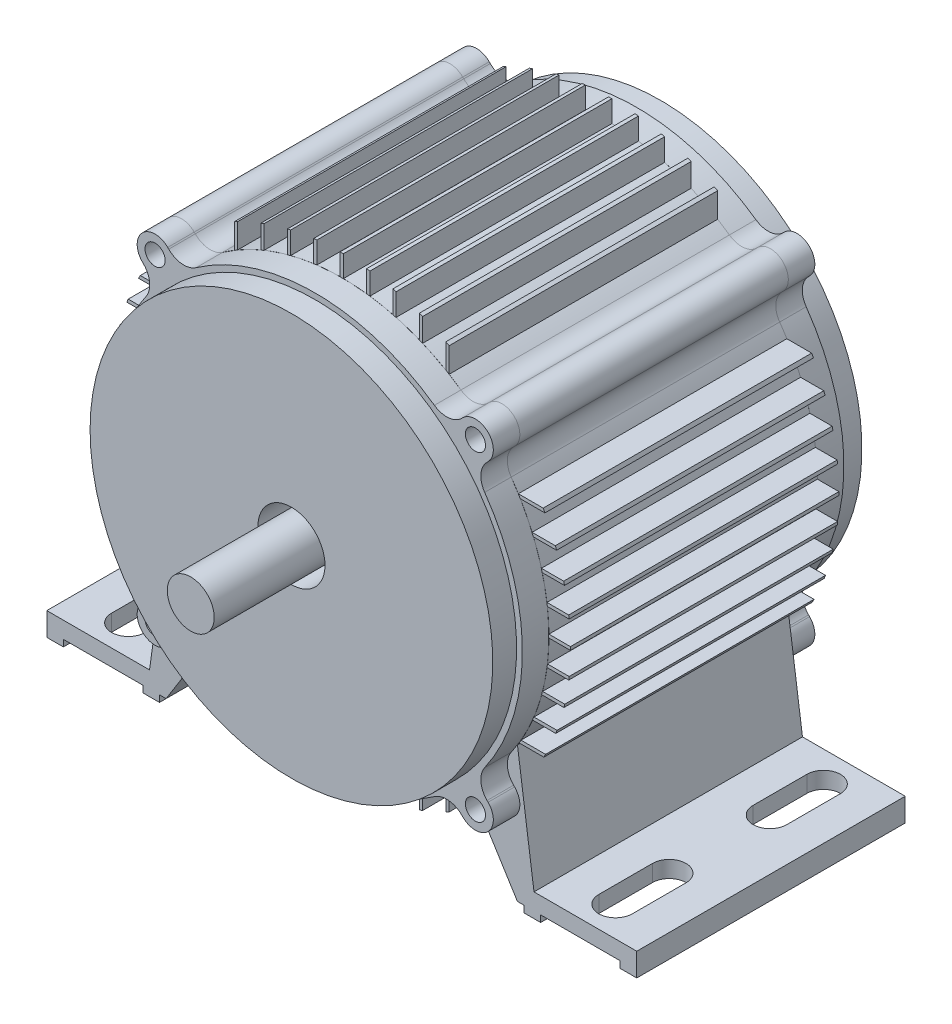
from build123d import *

# Parameters (mm, degrees)
SKETCH2_R           = 3.001904892
BOSS_EXTRUDE1_DEPTH = 40
SKETCH3_R           = 3.001904892
BOSS_EXTRUDE2_DEPTH = 7.90123449
SKETCH4_R           = 60
BOSS_EXTRUDE3_DEPTH = 7.09876741
SKETCH5_R           = 10
CUT_EXTRUDE1_DEPTH  = 10
SKETCH6_R           = 7
BOSS_EXTRUDE4_DEPTH = 40
CUT_EXTRUDE2_DEPTH  = 7.913590238


with BuildPart() as part:
    # Sketch2 → Boss-Extrude1 (new body, symmetric)
    with BuildSketch(Plane.XY):
        with BuildLine():
            Line((-51.501415301, 43.958000159), (-51.19613283, 43.652717688))
            ThreePointArc((-51.19613283, 43.652717688), (-49.359859691, 39.709533744), (-50.492135081, 35.509706236))
            ThreePointArc((-50.492135081, 35.509706236), (-51.583521776, 33.904796461), (-52.623914304, 32.266369261))
            Line((-52.623914304, 32.266369261), (-60.023406434, 32.266366121))
            ThreePointArc((-60.023406434, 32.266366121), (-60.2857042, 31.773598658), (-60.543956635, 31.278699103))
            Line((-60.543956635, 31.278699103), (-53.216893089, 31.278718144))
            ThreePointArc((-53.216893089, 31.278718144), (-55.075175316, 27.876889761), (-56.71627077, 24.365130246))
            Line((-56.71627077, 24.365130246), (-63.641714651, 24.365136135))
            ThreePointArc((-63.641714651, 24.365136135), (-63.828318371, 23.872022883), (-64.011101381, 23.377480672))
            Line((-64.011101381, 23.377480672), (-57.130453877, 23.377471671))
            ThreePointArc((-57.130453877, 23.377471671), (-58.413752932, 19.955661112), (-59.492308567, 16.463904862))
            Line((-59.492308567, 16.463904862), (-66.127663112, 16.463896075))
            ThreePointArc((-66.127663112, 16.463896075), (-66.248550527, 15.970512068), (-66.365756817, 15.476240653))
            Line((-66.365756817, 15.476240653), (-59.756854028, 15.47624901))
            ThreePointArc((-59.756854028, 15.47624901), (-60.550785596, 11.999927103), (-61.142654022, 8.48356064))
            Line((-61.142654022, 8.48356064), (-67.616248118, 8.483554267))
            ThreePointArc((-67.616248118, 8.483554267), (-67.676351394, 7.989941467), (-67.732851241, 7.495903243))
            Line((-67.732851241, 7.495903243), (-61.27157941, 7.495898782))
            ThreePointArc((-61.27157941, 7.495898782), (-61.595689717, 4.045485161), (-61.725649816, 0.58232013))
            Line((-61.725649816, 0.58232013), (-68.14388164, 0.582320874))
            ThreePointArc((-68.14388164, 0.582320874), (-68.146312234, 0.088496103), (-68.145164227, -0.405333315))
            Line((-68.145164227, -0.405333315), (-61.727065744, -0.405335092))
            ThreePointArc((-61.727065744, -0.405335092), (-61.607076082, -3.868219042), (-61.29297209, -7.318914833))
            Line((-61.29297209, -7.318914833), (-67.752204396, -7.318914))
            ThreePointArc((-67.752204396, -7.318914), (-67.697012719, -7.812948967), (-67.63821869, -8.306568185))
            Line((-67.63821869, -8.306568185), (-61.166950622, -8.306569298))
            ThreePointArc((-61.166950622, -8.306569298), (-60.603001045, -11.733337387), (-59.8472251, -15.122965889))
            Line((-59.8472251, -15.122965889), (-66.447149122, -15.12296519))
            ThreePointArc((-66.447149122, -15.12296519), (-66.332721065, -15.617228269), (-66.214616514, -16.110625762))
            Line((-66.214616514, -16.110625762), (-59.588945291, -16.110619219))
            ThreePointArc((-59.588945291, -16.110619219), (-58.533502121, -19.601621923), (-57.273737991, -23.024202017))
            Line((-57.273737991, -23.024202017), (-64.139023113, -23.024191988))
            ThreePointArc((-64.139023113, -23.024191988), (-63.959343175, -23.51871857), (-63.775850389, -24.011843116))
            Line((-63.775850389, -24.011843116), (-56.866737161, -24.011854294))
            ThreePointArc((-56.866737161, -24.011854294), (-55.253087395, -27.522559388), (-53.422959101, -30.925432622))
            Line((-53.422959101, -30.925432622), (-60.725164552, -30.925427932))
            ThreePointArc((-60.725164552, -30.925427932), (-60.470588944, -31.420305145), (-60.211980439, -31.91308688))
            Line((-60.211980439, -31.91308688), (-52.83890994, -31.913084215))
            ThreePointArc((-52.83890994, -31.913084215), (-52.600187977, -32.305039429), (-52.358555779, -32.695207274))
            Line((-52.358555779, -32.695207274), (-57.28396266, -68.148145721))
            Line((-57.28396266, -68.148145721), (-87.901233697, -68.148147473))
            Line((-87.901233697, -68.148147473), (-87.901233697, -75.061727651))
            Line((-87.901233697, -75.061727651), (-82.962962141, -75.061727651))
            Line((-82.962962141, -75.061727651), (-82.962962141, -73.086419029))
            Line((-82.962962141, -73.086419029), (-59.259258672, -73.086419029))
            Line((-59.259258672, -73.086419029), (-59.259258672, -75.061727651))
            Line((-59.259258672, -75.061727651), (-54.320987116, -75.061727651))
            Line((-54.320987116, -75.061727651), (-54.320987116, -73.086419029))
            Line((-54.320987116, -73.086419029), (-52.345682251, -73.086416681))
            Line((-52.345682251, -73.086416681), (-37.372511824, -49.129322221))
            ThreePointArc((-37.372511824, -49.129322221), (-34.735133697, -51.028084709), (-32.001482108, -52.785415456))
            Line((-32.001482108, -52.785415456), (-32.001488085, -60.16504353))
            ThreePointArc((-32.001488085, -60.16504353), (-31.508713442, -60.424570167), (-31.013834243, -60.680060878))
            Line((-31.013834243, -60.680060878), (-31.013830274, -53.371689815))
            ThreePointArc((-31.013830274, -53.371689815), (-27.611209789, -55.208840197), (-24.100235977, -56.829337211))
            Line((-24.100235977, -56.829337211), (-24.100239197, -63.742498957))
            ThreePointArc((-24.100239197, -63.742498957), (-23.607122651, -63.926766403), (-23.11259739, -64.107219129))
            Line((-23.11259739, -64.107219129), (-23.112585448, -57.23812834))
            ThreePointArc((-23.112585448, -57.23812834), (-19.690202448, -58.503767994), (-16.199016562, -59.564979681))
            Line((-16.199016562, -59.564979681), (-16.199011276, -66.193049003))
            ThreePointArc((-16.199011276, -66.193049003), (-15.705621383, -66.311847807), (-15.211360474, -66.426969035))
            Line((-15.211360474, -66.426969035), (-15.21136167, -59.824822759))
            ThreePointArc((-15.21136167, -59.824822759), (-11.821929932, -60.585781456), (-8.395058809, -61.154868404))
            Line((-8.395058809, -61.154868404), (-8.395063641, -67.627291895))
            ThreePointArc((-8.395063641, -67.627291895), (-7.901445328, -67.686740683), (-7.407406427, -67.742586551))
            Line((-7.407406427, -67.742586551), (-7.407405553, -61.282344658))
            ThreePointArc((-7.407405553, -61.282344658), (-3.95685085, -61.601450918), (-0.493826306, -61.726421227))
            Line((-0.493826306, -61.726421227), (-0.493827155, -68.144580396))
            ThreePointArc((-0.493827155, -68.144580396), (0, -68.146369695), (0.493827155, -68.144580396))
            Line((0.493827155, -68.144580396), (0.493826306, -61.726421227))
            ThreePointArc((0.493826306, -61.726421227), (3.95685085, -61.601450918), (7.407405553, -61.282344658))
            Line((7.407405553, -61.282344658), (7.407406427, -67.742586551))
            ThreePointArc((7.407406427, -67.742586551), (7.901445328, -67.686740683), (8.395063641, -67.627291895))
            Line((8.395063641, -67.627291895), (8.395058809, -61.154868404))
            ThreePointArc((8.395058809, -61.154868404), (11.821929932, -60.585781456), (15.21136167, -59.824822759))
            Line((15.21136167, -59.824822759), (15.211360474, -66.426969035))
            ThreePointArc((15.211360474, -66.426969035), (15.705621383, -66.311847807), (16.199011276, -66.193049003))
            Line((16.199011276, -66.193049003), (16.199016562, -59.564979681))
            ThreePointArc((16.199016562, -59.564979681), (19.690202448, -58.503767994), (23.112585448, -57.23812834))
            Line((23.112585448, -57.23812834), (23.11259739, -64.107219129))
            ThreePointArc((23.11259739, -64.107219129), (23.607122651, -63.926766403), (24.100239197, -63.742498957))
            Line((24.100239197, -63.742498957), (24.100235977, -56.829337211))
            ThreePointArc((24.100235977, -56.829337211), (27.611209789, -55.208840197), (31.013830274, -53.371689815))
            Line((31.013830274, -53.371689815), (31.013834243, -60.680060878))
            ThreePointArc((31.013834243, -60.680060878), (31.508713442, -60.424570167), (32.001488085, -60.16504353))
            Line((32.001488085, -60.16504353), (32.001482108, -52.785415456))
            ThreePointArc((32.001482108, -52.785415456), (34.735133697, -51.028084709), (37.372511824, -49.129322221))
            Line((37.372511824, -49.129322221), (52.345682251, -73.086416681))
            Line((52.345682251, -73.086416681), (54.320987116, -73.086419029))
            Line((54.320987116, -73.086419029), (54.320987116, -75.061727651))
            Line((54.320987116, -75.061727651), (59.259258672, -75.061727651))
            Line((59.259258672, -75.061727651), (59.259258672, -73.086419029))
            Line((59.259258672, -73.086419029), (82.962962141, -73.086419029))
            Line((82.962962141, -73.086419029), (82.962962141, -75.061727651))
            Line((82.962962141, -75.061727651), (87.901233697, -75.061727651))
            Line((87.901233697, -75.061727651), (87.901233697, -68.148147473))
            Line((87.901233697, -68.148147473), (57.28396266, -68.148145721))
            Line((57.28396266, -68.148145721), (52.358555779, -32.695207274))
            ThreePointArc((52.358555779, -32.695207274), (52.600187977, -32.305039429), (52.83890994, -31.913084215))
            Line((52.83890994, -31.913084215), (60.211980439, -31.91308688))
            ThreePointArc((60.211980439, -31.91308688), (60.470588944, -31.420305145), (60.725164552, -30.925427932))
            Line((60.725164552, -30.925427932), (53.422959101, -30.925432622))
            ThreePointArc((53.422959101, -30.925432622), (55.253087395, -27.522559388), (56.866737161, -24.011854294))
            Line((56.866737161, -24.011854294), (63.775850389, -24.011843116))
            ThreePointArc((63.775850389, -24.011843116), (63.959343175, -23.51871857), (64.139023113, -23.024191988))
            Line((64.139023113, -23.024191988), (57.273737991, -23.024202017))
            ThreePointArc((57.273737991, -23.024202017), (58.533502121, -19.601621923), (59.588945291, -16.110619219))
            Line((59.588945291, -16.110619219), (66.214616514, -16.110625762))
            ThreePointArc((66.214616514, -16.110625762), (66.332721065, -15.617228269), (66.447149122, -15.12296519))
            Line((66.447149122, -15.12296519), (59.8472251, -15.122965889))
            ThreePointArc((59.8472251, -15.122965889), (60.603001045, -11.733337387), (61.166950622, -8.306569298))
            Line((61.166950622, -8.306569298), (67.63821869, -8.306568185))
            ThreePointArc((67.63821869, -8.306568185), (67.697012719, -7.812948967), (67.752204396, -7.318914))
            Line((67.752204396, -7.318914), (61.29297209, -7.318914833))
            ThreePointArc((61.29297209, -7.318914833), (61.607076082, -3.868219042), (61.727065744, -0.405335092))
            Line((61.727065744, -0.405335092), (68.145164227, -0.405333315))
            ThreePointArc((68.145164227, -0.405333315), (68.146312234, 0.088496103), (68.14388164, 0.582320874))
            Line((68.14388164, 0.582320874), (61.725649816, 0.58232013))
            ThreePointArc((61.725649816, 0.58232013), (61.595689717, 4.045485161), (61.27157941, 7.495898782))
            Line((61.27157941, 7.495898782), (67.732851241, 7.495903243))
            ThreePointArc((67.732851241, 7.495903243), (67.676351394, 7.989941467), (67.616248118, 8.483554267))
            Line((67.616248118, 8.483554267), (61.142654022, 8.48356064))
            ThreePointArc((61.142654022, 8.48356064), (60.550785596, 11.999927103), (59.756854028, 15.47624901))
            Line((59.756854028, 15.47624901), (66.365756817, 15.476240653))
            ThreePointArc((66.365756817, 15.476240653), (66.248550527, 15.970512068), (66.127663112, 16.463896075))
            Line((66.127663112, 16.463896075), (59.492308567, 16.463904862))
            ThreePointArc((59.492308567, 16.463904862), (58.413752932, 19.955661112), (57.130453877, 23.377471671))
            Line((57.130453877, 23.377471671), (64.011101381, 23.377480672))
            ThreePointArc((64.011101381, 23.377480672), (63.828318371, 23.872022883), (63.641714651, 24.365136135))
            Line((63.641714651, 24.365136135), (56.71627077, 24.365130246))
            ThreePointArc((56.71627077, 24.365130246), (55.075175316, 27.876889761), (53.216893089, 31.278718144))
            Line((53.216893089, 31.278718144), (60.543956635, 31.278699103))
            ThreePointArc((60.543956635, 31.278699103), (60.2857042, 31.773598658), (60.023406434, 32.266366121))
            Line((60.023406434, 32.266366121), (52.623914304, 32.266369261))
            ThreePointArc((52.623914304, 32.266369261), (51.583521776, 33.904796461), (50.492135081, 35.509706236))
            ThreePointArc((50.492135081, 35.509706236), (49.359859691, 39.709533744), (51.19613283, 43.652717688))
            Line((51.19613283, 43.652717688), (51.501415301, 43.958000159))
            ThreePointArc((51.501415301, 43.958000159), (51.501415301, 51.501415301), (43.958000159, 51.501415301))
            Line((43.958000159, 51.501415301), (43.652717688, 51.19613283))
            ThreePointArc((43.652717688, 51.19613283), (39.709533744, 49.359859691), (35.509706236, 50.492135081))
            ThreePointArc((35.509706236, 50.492135081), (33.775063613, 51.668559298), (32.001482121, 52.785415448))
            Line((32.001482121, 52.785415448), (32.001488085, 60.16504353))
            ThreePointArc((32.001488085, 60.16504353), (31.508709762, 60.424572086), (31.013826853, 60.680064655))
            Line((31.013826853, 60.680064655), (31.013827871, 53.371691211))
            ThreePointArc((31.013827871, 53.371691211), (27.611219196, 55.208835493), (24.100257901, 56.829327913))
            Line((24.100257901, 56.829327913), (24.100241647, 63.742498031))
            ThreePointArc((24.100241647, 63.742498031), (23.607118973, 63.926767761), (23.112587551, 64.107222677))
            Line((23.112587551, 64.107222677), (23.112590461, 57.238117875))
            ThreePointArc((23.112590461, 57.238117875), (19.690201595, 58.503768281), (16.199006783, 59.56498234))
            Line((16.199006783, 59.56498234), (16.199011275, 66.193049003))
            ThreePointArc((16.199011275, 66.193049003), (15.70561733, 66.311848767), (15.211352356, 66.426970894))
            Line((15.211352356, 66.426970894), (15.211362204, 59.824817373))
            ThreePointArc((15.211362204, 59.824817373), (11.821931396, 60.58578117), (8.39506008, 61.15486823))
            Line((8.39506008, 61.15486823), (8.395062775, 67.627292003))
            ThreePointArc((8.395062775, 67.627292003), (7.901446757, 67.686740517), (7.407410155, 67.742586144))
            Line((7.407410155, 67.742586144), (7.407408185, 61.282340408))
            ThreePointArc((7.407408185, 61.282340408), (3.956852898, 61.601446875), (0.493827901, 61.726421215))
            Line((0.493827901, 61.726421215), (0.493827156, 68.144580396))
            ThreePointArc((0.493827156, 68.144580396), (0, 68.146369695), (-0.493827156, 68.144580396))
            Line((-0.493827156, 68.144580396), (-0.493827901, 61.726421215))
            ThreePointArc((-0.493827901, 61.726421215), (-3.956852898, 61.601446875), (-7.407408185, 61.282340408))
            Line((-7.407408185, 61.282340408), (-7.407410155, 67.742586144))
            ThreePointArc((-7.407410155, 67.742586144), (-7.901446757, 67.686740517), (-8.395062775, 67.627292003))
            Line((-8.395062775, 67.627292003), (-8.39506008, 61.15486823))
            ThreePointArc((-8.39506008, 61.15486823), (-11.821931396, 60.58578117), (-15.211362204, 59.824817373))
            Line((-15.211362204, 59.824817373), (-15.211352356, 66.426970894))
            ThreePointArc((-15.211352356, 66.426970894), (-15.70561733, 66.311848767), (-16.199011275, 66.193049003))
            Line((-16.199011275, 66.193049003), (-16.199006783, 59.56498234))
            ThreePointArc((-16.199006783, 59.56498234), (-19.690201595, 58.503768281), (-23.112590461, 57.238117875))
            Line((-23.112590461, 57.238117875), (-23.112587551, 64.107222677))
            ThreePointArc((-23.112587551, 64.107222677), (-23.607118973, 63.926767761), (-24.100241647, 63.742498031))
            Line((-24.100241647, 63.742498031), (-24.100257901, 56.829327913))
            ThreePointArc((-24.100257901, 56.829327913), (-27.611219196, 55.208835493), (-31.013827871, 53.371691211))
            Line((-31.013827871, 53.371691211), (-31.013826853, 60.680064655))
            ThreePointArc((-31.013826853, 60.680064655), (-31.508709762, 60.424572086), (-32.001488085, 60.16504353))
            Line((-32.001488085, 60.16504353), (-32.001482121, 52.785415448))
            ThreePointArc((-32.001482121, 52.785415448), (-33.775063613, 51.668559298), (-35.509706236, 50.492135081))
            ThreePointArc((-35.509706236, 50.492135081), (-39.709533744, 49.359859691), (-43.652717688, 51.19613283))
            Line((-43.652717688, 51.19613283), (-43.958000159, 51.501415301))
            ThreePointArc((-43.958000159, 51.501415301), (-51.501415301, 51.501415301), (-51.501415301, 43.958000159))
        make_face()
        with Locations((-47.72970773, 47.72970773)):
            Circle(SKETCH2_R, mode=Mode.SUBTRACT)
        with Locations((47.72970773, 47.72970773)):
            Circle(SKETCH2_R, mode=Mode.SUBTRACT)
    extrude(amount=BOSS_EXTRUDE1_DEPTH, both=True)

    # Sketch7 → Cut-Extrude2 (cut, through all)
    with BuildSketch(Plane(origin=(3.9e-06, -68.148142443, 0), x_dir=(1, 5.7e-08, 0), z_dir=(-5.7e-08, 1, 0))):
        with BuildLine():
            Line((-67.592602078, 31), (-67.592602078, 15))
            ThreePointArc((-67.592602078, 15), (-72.592602078, 10), (-77.592602078, 15))
            Line((-77.592602078, 15), (-77.592602078, 31))
            ThreePointArc((-77.592602078, 31), (-72.592602078, 36), (-67.592602078, 31))
        make_face()
        with BuildLine():
            Line((-67.592602078, -31), (-67.592602078, -15))
            ThreePointArc((-67.592602078, -15), (-72.592602078, -10), (-77.592602078, -15))
            Line((-77.592602078, -15), (-77.592602078, -31))
            ThreePointArc((-77.592602078, -31), (-72.592602078, -36), (-67.592602078, -31))
        make_face()
        with BuildLine():
            Line((67.592594279, 31), (67.592594279, 15))
            ThreePointArc((67.592594279, 15), (72.592594279, 10), (77.592594279, 15))
            Line((77.592594279, 15), (77.592594279, 31))
            ThreePointArc((77.592594279, 31), (72.592594279, 36), (67.592594279, 31))
        make_face()
        with BuildLine():
            Line((67.592594279, -31), (67.592594279, -15))
            ThreePointArc((67.592594279, -15), (72.592594279, -10), (77.592594279, -15))
            Line((77.592594279, -15), (77.592594279, -31))
            ThreePointArc((77.592594279, -31), (72.592594279, -36), (67.592594279, -31))
        make_face()
    extrude(amount=-CUT_EXTRUDE2_DEPTH, mode=Mode.SUBTRACT)


with BuildPart() as body_2:
    # Sketch3 → Boss-Extrude2 (new body)
    with BuildSketch(Plane(origin=(0, 0, -40), x_dir=(-1, 0, 0), z_dir=(0, 0, -1))):
        with BuildLine():
            Line((-51.19613283, 43.652717688), (-51.501415301, 43.958000159))
            ThreePointArc((-51.501415301, 43.958000159), (-51.501415301, 51.501415301), (-43.958000159, 51.501415301))
            Line((-43.958000159, 51.501415301), (-43.652717688, 51.19613283))
            ThreePointArc((-43.652717688, 51.19613283), (-39.709533744, 49.359859691), (-35.509706236, 50.492135081))
            ThreePointArc((-35.509706236, 50.492135081), (0, 61.728396561), (35.509706236, 50.492135081))
            ThreePointArc((35.509706236, 50.492135081), (39.709533744, 49.359859691), (43.652717688, 51.19613283))
            Line((43.652717688, 51.19613283), (43.958000159, 51.501415301))
            ThreePointArc((43.958000159, 51.501415301), (51.501415301, 51.501415301), (51.501415301, 43.958000159))
            Line((51.501415301, 43.958000159), (51.19613283, 43.652717688))
            ThreePointArc((51.19613283, 43.652717688), (49.359859691, 39.709533744), (50.492135081, 35.509706236))
            ThreePointArc((50.492135081, 35.509706236), (61.728396561, 0), (50.492135081, -35.509706236))
            ThreePointArc((50.492135081, -35.509706236), (49.359859691, -39.709533744), (51.19613283, -43.652717688))
            Line((51.19613283, -43.652717688), (51.501415301, -43.958000159))
            ThreePointArc((51.501415301, -43.958000159), (51.501415301, -51.501415301), (43.958000159, -51.501415301))
            Line((43.958000159, -51.501415301), (43.652717688, -51.19613283))
            ThreePointArc((43.652717688, -51.19613283), (39.709533744, -49.359859691), (35.509706236, -50.492135081))
            ThreePointArc((35.509706236, -50.492135081), (0, -61.728396561), (-35.509706236, -50.492135081))
            ThreePointArc((-35.509706236, -50.492135081), (-39.709533744, -49.359859691), (-43.652717688, -51.19613283))
            Line((-43.652717688, -51.19613283), (-43.958000159, -51.501415301))
            ThreePointArc((-43.958000159, -51.501415301), (-51.501415301, -51.501415301), (-51.501415301, -43.958000159))
            Line((-51.501415301, -43.958000159), (-51.19613283, -43.652717688))
            ThreePointArc((-51.19613283, -43.652717688), (-49.359859691, -39.709533744), (-50.492135081, -35.509706236))
            ThreePointArc((-50.492135081, -35.509706236), (-61.728396561, 0), (-50.492135081, 35.509706236))
            ThreePointArc((-50.492135081, 35.509706236), (-49.359859691, 39.709533744), (-51.19613283, 43.652717688))
        make_face()
        with Locations((-47.72970773, 47.72970773)):
            Circle(SKETCH3_R, mode=Mode.SUBTRACT)
        with Locations((47.72970773, 47.72970773)):
            Circle(SKETCH3_R, mode=Mode.SUBTRACT)
        with Locations((47.72970773, -47.72970773)):
            Circle(SKETCH3_R, mode=Mode.SUBTRACT)
        with Locations((-47.72970773, -47.72970773)):
            Circle(SKETCH3_R, mode=Mode.SUBTRACT)
    extrude(amount=BOSS_EXTRUDE2_DEPTH)

    # Sketch4 → Boss-Extrude3 (add)
    with BuildSketch(Plane(origin=(0, 0, -47.90123449), x_dir=(-1, 0, 0), z_dir=(0, 0, -1))):
        Circle(SKETCH4_R)
    extrude(amount=BOSS_EXTRUDE3_DEPTH)


with BuildPart() as body_3:
    # Mirror2: mirrored copy
    add(body_2.part.mirror(Plane.XY))

    # Sketch5 → Cut-Extrude1 (cut)
    with BuildSketch(Plane.XY.offset(55.0000019)):
        Circle(SKETCH5_R)
    extrude(amount=-CUT_EXTRUDE1_DEPTH, mode=Mode.SUBTRACT)

    # Sketch6 → Boss-Extrude4 (add)
    with BuildSketch(Plane.XY.offset(45.0000019)):
        Circle(SKETCH6_R)
    extrude(amount=BOSS_EXTRUDE4_DEPTH)


solid = Compound([part.part, body_2.part, body_3.part])
